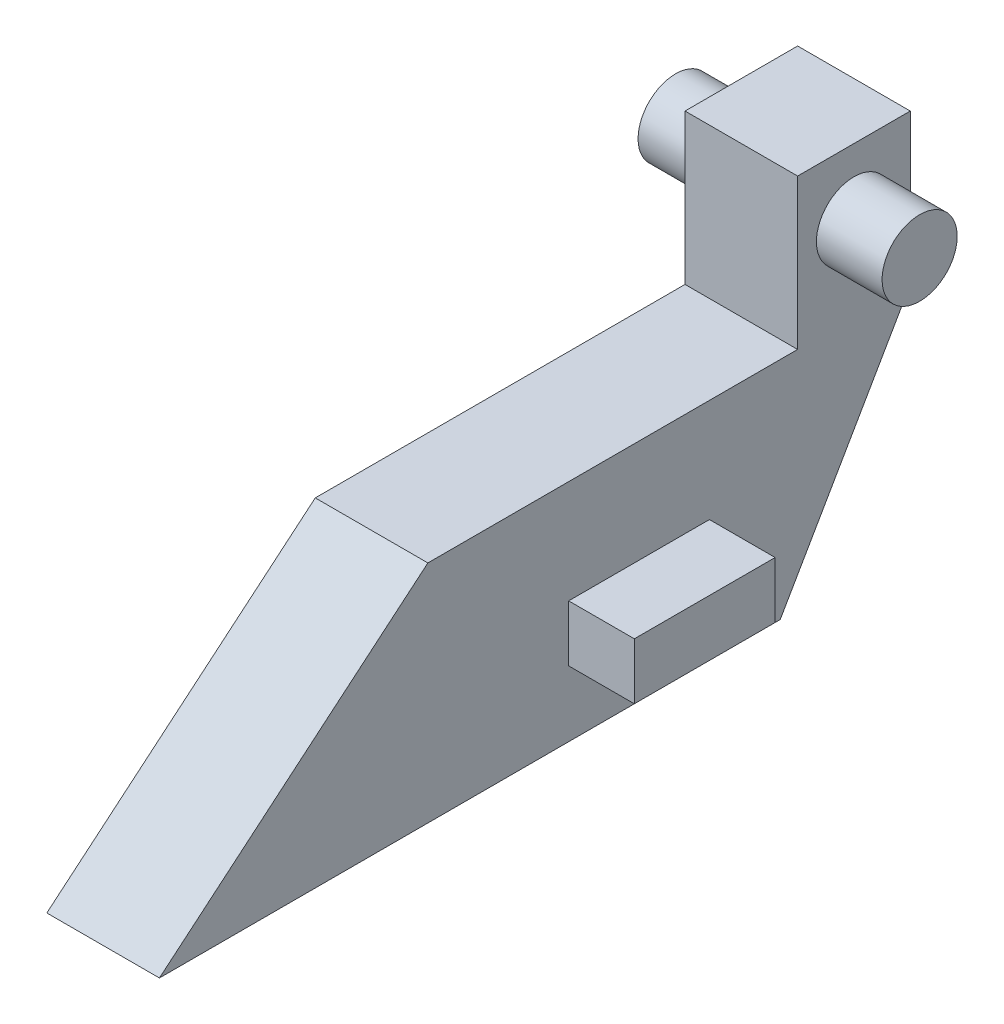
from build123d import *

# Parameters (mm, degrees)
SKETCH1_W           = 12
SKETCH1_H           = 24
BOSS_EXTRUDE1_DEPTH = 80
CUT_EXTRUDE1_DEPTH  = 12
SKETCH4_W           = 15
SKETCH4_H           = 6
BOSS_EXTRUDE2_DEPTH = 7
SKETCH5_W           = 12
SKETCH5_H           = 12
BOSS_EXTRUDE3_DEPTH = 16
SKETCH7_R           = 4
BOSS_EXTRUDE4_DEPTH = 13


with BuildPart() as part:
    # Sketch1 → Boss-Extrude1 (new body)
    with BuildSketch(Plane.XY):
        with Locations((0, 12)):
            Rectangle(SKETCH1_W, SKETCH1_H)
    extrude(amount=-BOSS_EXTRUDE1_DEPTH)

    # Sketch2 → Cut-Extrude1 (cut)
    with BuildSketch(Plane(origin=(6, 0, 0), x_dir=(0, 0, -1), z_dir=(1, 0, 0))):
        Polygon((0, 24), (0, 0), (28.602086222, 24), align=None)
        Polygon((80, 24), (66.143593539, 0), (80, 0), align=None)
    extrude(amount=-CUT_EXTRUDE1_DEPTH, mode=Mode.SUBTRACT)

    # Sketch4 → Boss-Extrude2 (add)
    with BuildSketch(Plane(origin=(6, 0, 0), x_dir=(0, 0, -1), z_dir=(1, 0, 0))):
        with Locations((51.102086222, 10)):
            Rectangle(SKETCH4_W, SKETCH4_H)
    boss_extrude2 = extrude(amount=BOSS_EXTRUDE2_DEPTH)

    # Mirror1: Boss-Extrude2 across plane
    add(boss_extrude2.mirror(Plane(origin=(0, 0, 0), x_dir=(0, 0, 1), z_dir=(1, 0, 0))))

    # Sketch5 → Boss-Extrude3 (add)
    with BuildSketch(Plane(origin=(0, 24, 0), x_dir=(1, 0, 0), z_dir=(0, 1, 0))):
        with Locations((0, 74)):
            Rectangle(SKETCH5_W, SKETCH5_H)
    extrude(amount=BOSS_EXTRUDE3_DEPTH)

    # Sketch7 → Boss-Extrude4 (add, symmetric)
    with BuildSketch(Plane(origin=(0, 0, 0), x_dir=(0, 0, -1), z_dir=(1, 0, 0))):
        with Locations((74, 32.938039716)):
            Circle(SKETCH7_R)
    extrude(amount=BOSS_EXTRUDE4_DEPTH, both=True)


solid = part.part
